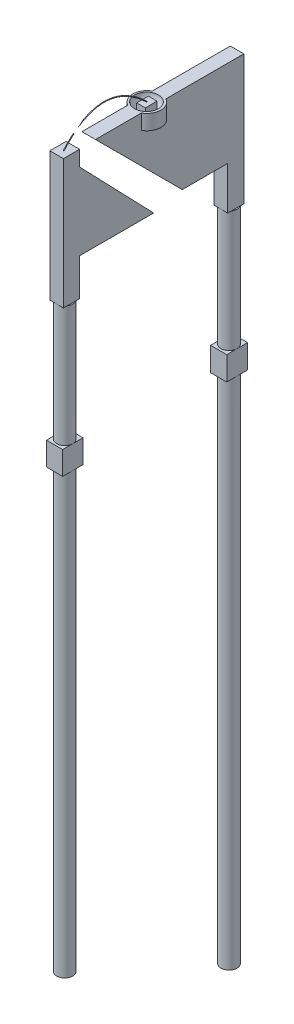
from build123d import *

# Parameters (mm, degrees)
SKETCH8_R                = 0.125
SKETCH10_R               = 0.125
BOSS_EXTRUDE2_DEPTH      = 10.164342442
BOSS_EXTRUDE4_DEPTH      = 0.105
BOSS_EXTRUDE4_DEPTH_BACK = 0.105
BOSS_EXTRUDE5_DEPTH      = 0.105
BOSS_EXTRUDE5_DEPTH_BACK = 0.105
SKETCH14_R               = 0.216263015
BOSS_EXTRUDE6_DEPTH      = 0.232915775
SKETCH18_W               = 0.133374126
SKETCH18_H               = 0.180742016
BOSS_EXTRUDE7_DEPTH      = 0.124766687
SWEEP2_PROFILE_R         = 0.005
SKETCH44_W               = 0.315151076
SKETCH44_H               = 0.179932759
SKETCH44_H_2             = 0.179932758
SKETCH44_W_2             = 0.321347092
SKETCH44_H_3             = 0.181986043
SKETCH44_H_4             = 0.184954596
BOSS_EXTRUDE8_DEPTH      = 0.02
BOSS_EXTRUDE8_DEPTH_BACK = 0.23


with BuildPart() as part:
    # Sweep1: sweep along a path in Sketch1
    with BuildLine(Plane(origin=(0, 0, 0), x_dir=(0, 0, -1), z_dir=(1, 0, 0))) as sweep1_path:
        Line((-1.27, 0), (-1.27, -9))
    # Sketch8 → Sweep1 (sweep)
    with BuildSketch(Plane(origin=(0, 0, 0), x_dir=(1, 0, 0), z_dir=(0, 1, 0))):
        with Locations((0, -1.27)):
            Circle(SKETCH8_R)
    sweep(path=sweep1_path.line)

    # Sketch12 → Boss-Extrude4 (add, two sides)
    with BuildSketch(Plane(origin=(0, 0, 0), x_dir=(0, 0, -1), z_dir=(1, 0, 0))) as boss_extrude4_sk:
        Polygon((-1.395, 0), (-1.395, 2), (-1.145, 2), (-1.145, 1.762321111), (0, 0.573744432), (-1.145, 0.573744432), (-1.145, 0), align=None)
    extrude(amount=BOSS_EXTRUDE4_DEPTH)
    extrude(boss_extrude4_sk.sketch, amount=-BOSS_EXTRUDE4_DEPTH_BACK)

    # Sweep2: sweep along a path in Sketch19
    with BuildLine() as sweep2_path:  # in the path sketch's own coordinates; laid on its plane below (add() does not lay a ready-made edge on the line's plane)
        add(Edge.make_bspline(
            [(0, 2.012928426), (-0.696593311, 2.67791947), (-1.294532201, 1.988679327)],
            knots=[0, 0, 0, 1, 1, 1], degree=2))
    # Sweep2 profile (on start of the path) → Sweep2 (sweep)
    with BuildSketch(Plane(origin=(0, 2.012928426, 0), x_dir=(0, 0.7233238733646169, -0.6905089240703612), z_dir=(0, 0.6905089240703612, 0.7233238733646169))):
        Circle(SWEEP2_PROFILE_R)
    sweep(path=Plane(origin=(0, 0, 0), x_dir=(0, 0, -1), z_dir=(1, 0, 0)) * sweep2_path.line)



with BuildPart() as body_2:
    # Sketch10 → Boss-Extrude2 (new body)
    with BuildSketch(Plane(origin=(0, 0, 0), x_dir=(1, 0, 0), z_dir=(0, 1, 0))):
        with Locations(Location((0, 1.27, 0), (0, 0, 270))):
            Circle(SKETCH10_R)
    extrude(amount=-BOSS_EXTRUDE2_DEPTH)

    # Sketch13 → Boss-Extrude5 (add, two sides)
    with BuildSketch(Plane(origin=(0, 0, 0), x_dir=(0, 0, -1), z_dir=(1, 0, 0))) as boss_extrude5_sk:
        Polygon((1.145, 0), (1.145, 0.665947897), (0.44260257, 0.665947897), (-0.899385322, 2.007935789), (1.27, 2.007935789), (1.395, 2.007935789), (1.395, 0), align=None)
    extrude(amount=BOSS_EXTRUDE5_DEPTH)
    extrude(boss_extrude5_sk.sketch, amount=-BOSS_EXTRUDE5_DEPTH_BACK)

    # Sketch14 → Boss-Extrude6 (add)
    with BuildSketch(Plane(origin=(0, 2.007935789, 0), x_dir=(1, 0, 0), z_dir=(0, 1, 0))):
        Circle(SKETCH14_R)
    extrude(amount=-BOSS_EXTRUDE6_DEPTH)

    # Sketch15 → Cut-Revolve8 (revolve, cut)
    with BuildSketch(Plane.XY):
        with BuildLine():
            Line((0.178837074, 2.007935789), (-0.19031102, 2.007935789))
            ThreePointArc((-0.19031102, 2.007935789), (-0.005736973, 1.823361742), (0.178837074, 2.007935789))
        make_face()
    revolve(axis=Axis((0.178837074, 2.007935789, 0), (-1, 0, 0)), mode=Mode.SUBTRACT)


with BuildPart() as body_3:
    # Sketch18 → Boss-Extrude7 (new body)
    with BuildSketch(Plane(origin=(0, 2.007935789, 0), x_dir=(1, 0, 0), z_dir=(0, 1, 0))):
        Rectangle(SKETCH18_W, SKETCH18_H)
    extrude(amount=-BOSS_EXTRUDE7_DEPTH)


with BuildPart() as part_1:
    add(part.part)

    add(body_2.part)  # Boss-Extrude8 merges body 2
    # Sketch44 → Boss-Extrude8 (add, two sides)
    with BuildSketch(Plane(origin=(0.105, 0, 0), x_dir=(0, 0, -1), z_dir=(1, 0, 0))) as boss_extrude8_sk:
        with Locations((-1.27, -2.139842094)):
            Rectangle(SKETCH44_W, SKETCH44_H)
        with Locations((-1.27, -1.959909335)):
            Rectangle(SKETCH44_W, SKETCH44_H_2)
        with Locations((1.271121429, -1.958882693)):
            Rectangle(SKETCH44_W_2, SKETCH44_H_3)
        with Locations((1.271121429, -2.142353012)):
            Rectangle(SKETCH44_W_2, SKETCH44_H_4)
    extrude(amount=BOSS_EXTRUDE8_DEPTH)
    extrude(boss_extrude8_sk.sketch, amount=-BOSS_EXTRUDE8_DEPTH_BACK)


solid = Compound([body_3.part, part_1.part])
